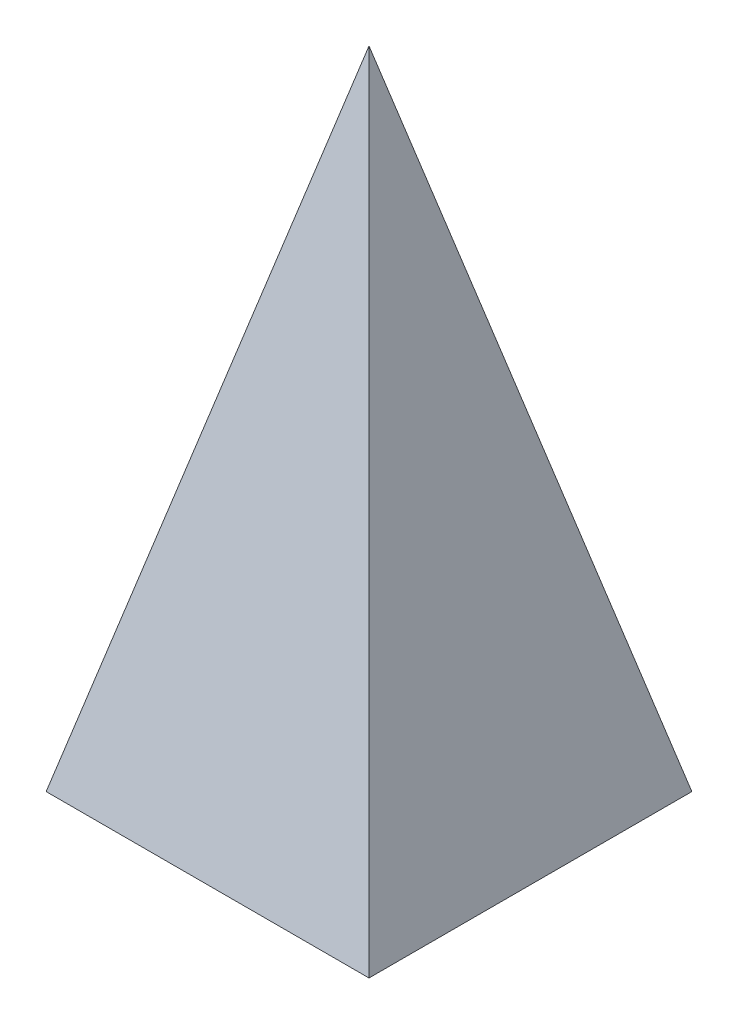
from build123d import *

# Parameters (mm, degrees)
SKETCH1_W = 10
SKETCH1_H = 10


with BuildPart() as part:
    # Sketch1 → Loft1 section 0
    with BuildSketch(Plane(origin=(0, 0, 0), x_dir=(1, 0, 0), z_dir=(0, 1, 0)), mode=Mode.PRIVATE) as loft1_s0:
        Rectangle(SKETCH1_W, SKETCH1_H)
    loft([Vertex(0, 20, 0), loft1_s0.sketch])


solid = part.part
